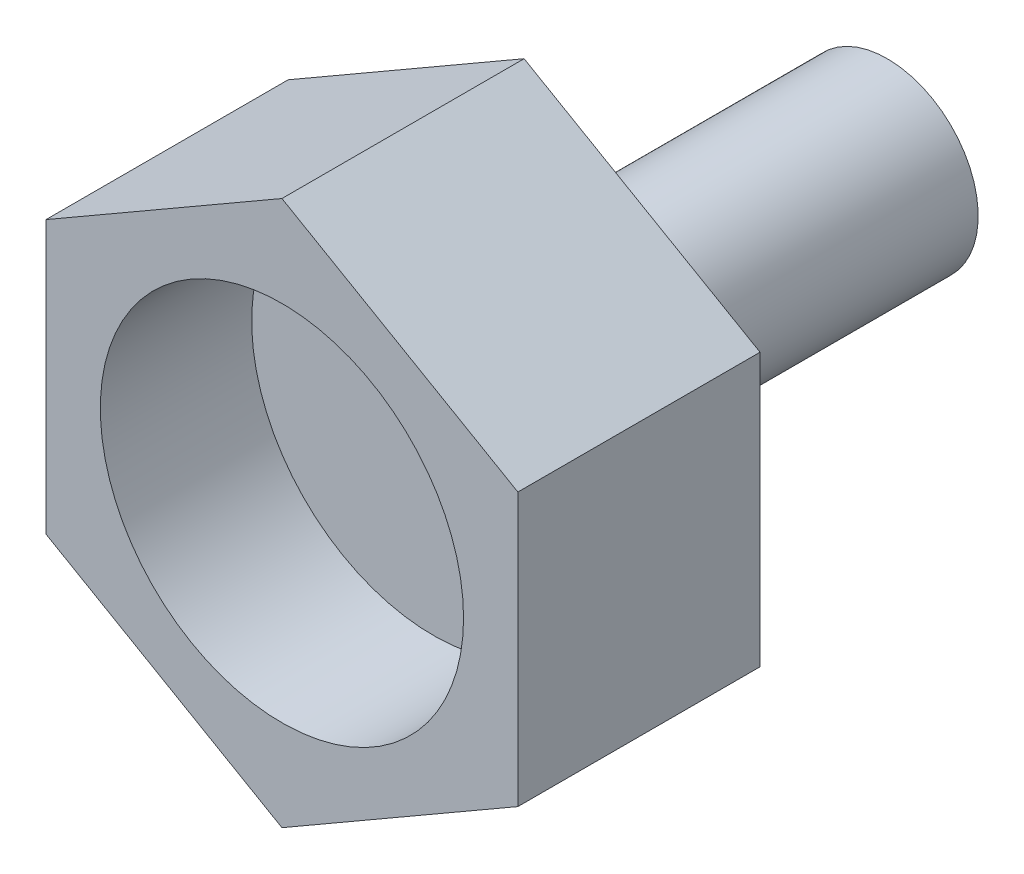
from build123d import *

# Parameters (mm, degrees)
EXTRUDE_1_DEPTH     = 4
SKETCH_3_R          = 1.5
EXTRUDE_2_DEPTH     = 6
SKETCH_4_R          = 3
CUT_EXTRUDE_1_DEPTH = 2.5


with BuildPart() as part:
    # ｽｹｯﾁ2 → ﾎﾞｽ - 押し出し1 (new body)
    with BuildSketch(Plane.XY):
        Polygon((3.897114317, -2.25), (3.897114317, 2.25), (0, 4.5), (-3.897114317, 2.25), (-3.897114317, -2.25), (0, -4.5), align=None)
    extrude(amount=EXTRUDE_1_DEPTH)

    # ｽｹｯﾁ3 → ﾎﾞｽ - 押し出し2 (add)
    with BuildSketch(Plane(origin=(0, 0, 0), x_dir=(-1, 0, 0), z_dir=(0, 0, -1))):
        Circle(SKETCH_3_R)
    extrude(amount=EXTRUDE_2_DEPTH)

    # ｽｹｯﾁ4 → ｶｯﾄ - 押し出し1 (cut)
    with BuildSketch(Plane.XY.offset(4)):
        Circle(SKETCH_4_R)
    extrude(amount=-CUT_EXTRUDE_1_DEPTH, mode=Mode.SUBTRACT)


solid = part.part
